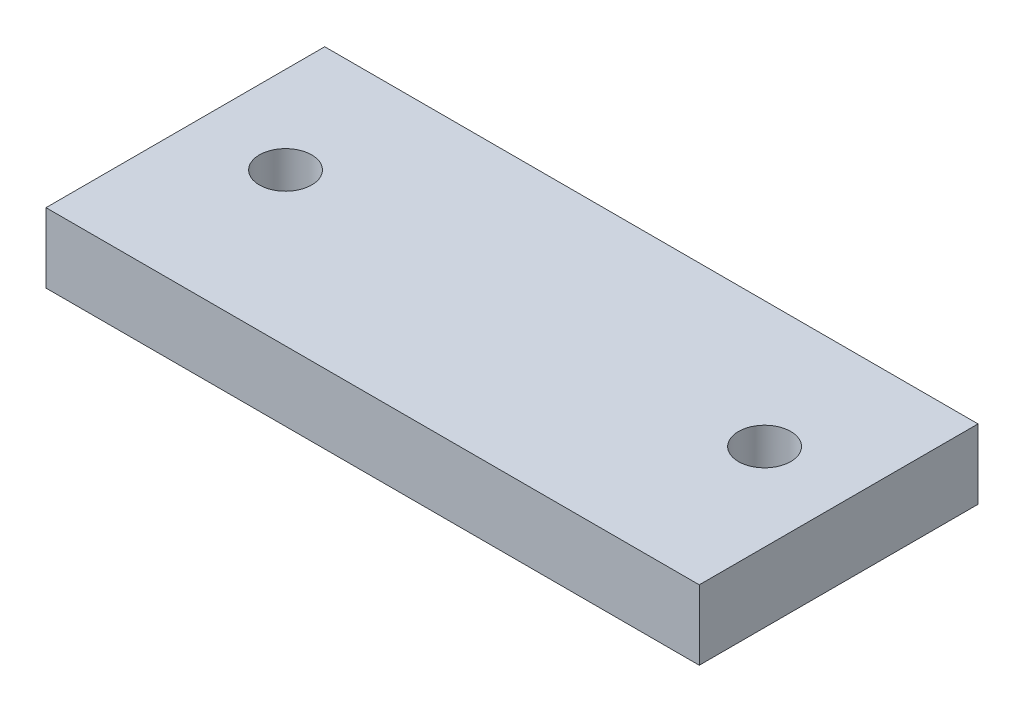
from build123d import *

# Parameters (mm, degrees)
SKETCH1_W           = 15
SKETCH1_H           = 4
BOSS_EXTRUDE1_DEPTH = 1.6
SKETCH5_W           = 15
SKETCH5_H           = 1.6
BOSS_EXTRUDE4_DEPTH = 1.5
SKETCH6_W           = 15
SKETCH6_H           = 1.6
BOSS_EXTRUDE5_DEPTH = 0.9
SKETCH8_R           = 0.6
CUT_EXTRUDE1_DEPTH  = 10


with BuildPart() as part:
    # Sketch1 → Boss-Extrude1 (new body)
    with BuildSketch(Plane(origin=(0, 0, 0), x_dir=(1, 0, 0), z_dir=(0, 1, 0))):
        Rectangle(SKETCH1_W, SKETCH1_H)
    extrude(amount=BOSS_EXTRUDE1_DEPTH)

    # Sketch5 → Boss-Extrude4 (add)
    with BuildSketch(Plane.XY.offset(2)):
        with Locations((0, 0.8)):
            Rectangle(SKETCH5_W, SKETCH5_H)
    extrude(amount=BOSS_EXTRUDE4_DEPTH)

    # Sketch6 → Boss-Extrude5 (add)
    with BuildSketch(Plane(origin=(0, 0, -2), x_dir=(-1, 0, 0), z_dir=(0, 0, -1))):
        with Locations((0, 0.8)):
            Rectangle(SKETCH6_W, SKETCH6_H)
    extrude(amount=BOSS_EXTRUDE5_DEPTH)

    # Sketch8 → Cut-Extrude1 (cut)
    with BuildSketch(Plane(origin=(0, 1.6, 0), x_dir=(1, 0, 0), z_dir=(0, 1, 0))):
        with Locations((5.5, 0)):
            Circle(SKETCH8_R)
        with Locations((-5.5, 0)):
            Circle(SKETCH8_R)
    extrude(amount=-CUT_EXTRUDE1_DEPTH, mode=Mode.SUBTRACT)


solid = part.part
